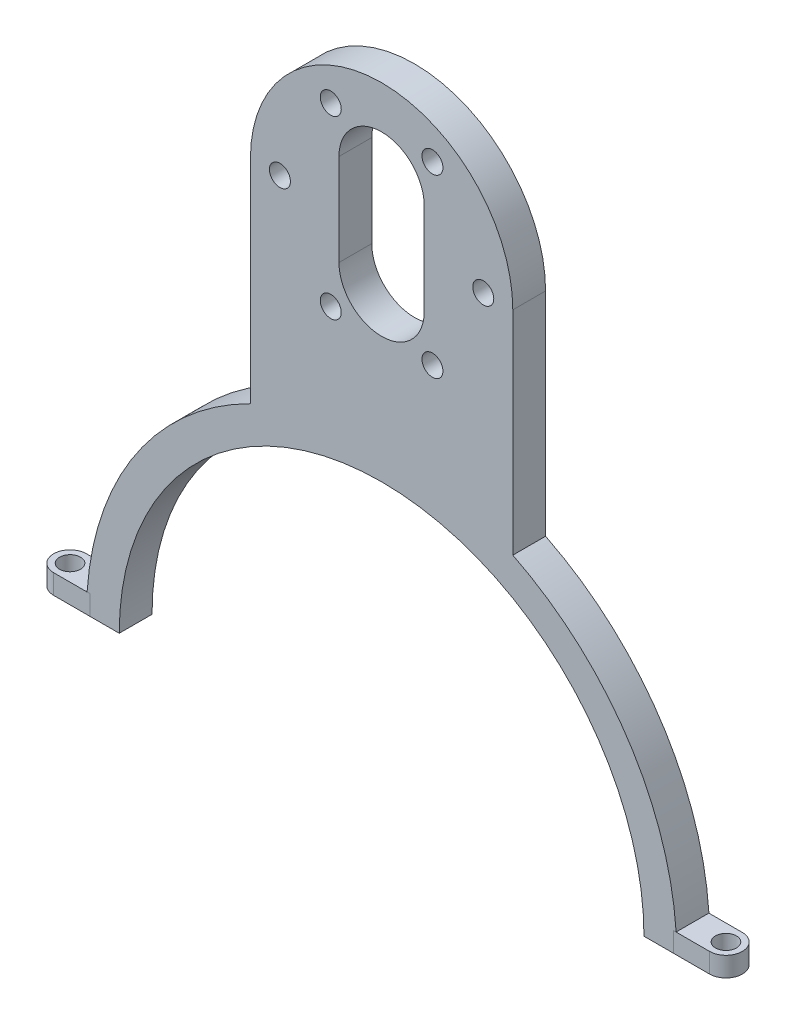
from build123d import *

# Parameters (mm, degrees)
SKETCH_1_R               = 40
EXTRUDE_1_DEPTH          = 5
SKETCH_2_R               = 1.6
CUT_EXTRUDE_1_DEPTH      = 5
SKETCH_3_R               = 2.6
CUT_EXTRUDE_2_DEPTH      = 2
SKETCH_4_W               = 99.26232013
SKETCH_4_H               = 51.828911565
CUT_EXTRUDE_3_DEPTH      = 1
CUT_EXTRUDE_3_DEPTH_BACK = 6
SKETCH_5_R               = 1.6
EXTRUDE_2_DEPTH          = 3
EXTRUDE_2_2_DEPTH        = 3


with BuildPart() as part:
    # 草图1 → 凸台-拉伸1 (new body)
    with BuildSketch(Plane.XY):
        with BuildLine():
            Line((-20, 72.7), (-20, 40.311288741))
            ThreePointArc((-20, 40.311288741), (0, -45), (20, 40.311288741))
            Line((20, 40.311288741), (20, 72.7))
            ThreePointArc((20, 72.7), (0, 92.7), (-20, 72.7))
        make_face()
        Circle(SKETCH_1_R, mode=Mode.SUBTRACT)
    extrude(amount=EXTRUDE_1_DEPTH)

    # 草图2 → 切除-拉伸1 (cut, symmetric)
    with BuildSketch(Plane.XY.offset(5)):
        with Locations((-7.75, 86.123393759)):
            Circle(SKETCH_2_R)
        with Locations((7.75, 86.123393759)):
            Circle(SKETCH_2_R)
        with Locations((15.5, 72.7)):
            Circle(SKETCH_2_R)
        with Locations((7.75, 59.276606241)):
            Circle(SKETCH_2_R)
        with Locations((-7.75, 59.276606241)):
            Circle(SKETCH_2_R)
        with Locations((-15.5, 72.7)):
            Circle(SKETCH_2_R)
        with BuildLine():
            Line((6.5, 79.7), (6.5, 65.7))
            ThreePointArc((6.5, 65.7), (0, 59.2), (-6.5, 65.7))
            Line((-6.5, 65.7), (-6.5, 79.7))
            ThreePointArc((-6.5, 79.7), (0, 86.2), (6.5, 79.7))
        make_face()
    extrude(amount=CUT_EXTRUDE_1_DEPTH, both=True, mode=Mode.SUBTRACT)

    # 草图3 → 切除-拉伸2 (cut)
    with BuildSketch(Plane(origin=(0, 0, 0), x_dir=(-1, 0, 0), z_dir=(0, 0, -1))):
        with Locations((-7.75, 86.123393759)):
            Circle(SKETCH_3_R)
        with Locations((7.75, 86.123393759)):
            Circle(SKETCH_3_R)
        with Locations((15.5, 72.7)):
            Circle(SKETCH_3_R)
        with Locations((7.75, 59.276606241)):
            Circle(SKETCH_3_R)
        with Locations((-7.75, 59.276606241)):
            Circle(SKETCH_3_R)
        with Locations((-15.5, 72.7)):
            Circle(SKETCH_3_R)
    extrude(amount=-CUT_EXTRUDE_2_DEPTH, mode=Mode.SUBTRACT)

    # 草图4 → 切除-拉伸3 (cut, two sides)
    with BuildSketch(Plane.XY.offset(5)) as cut_extrude_3_sk:
        with Locations((4.631160065, -25.914455783)):
            Rectangle(SKETCH_4_W, SKETCH_4_H)
    extrude(amount=CUT_EXTRUDE_3_DEPTH, mode=Mode.SUBTRACT)
    extrude(cut_extrude_3_sk.sketch, amount=-CUT_EXTRUDE_3_DEPTH_BACK, mode=Mode.SUBTRACT)


with BuildPart() as body_2:
    # 草图5 → 凸台-拉伸2 (new body)
    with BuildSketch(Plane.XZ):
        with BuildLine():
            Line((-44.472472542, 5.000003), (-50, 5.000003))
            ThreePointArc((-50, 5.000003), (-52.5, 2.500003), (-50, 3e-06))
            Line((-50, 3e-06), (-44.472472542, 3e-06))
            Line((-44.472472542, 3e-06), (-44.472472542, 5.000003))
        make_face()
        with Locations((-50, 2.500003)):
            Circle(SKETCH_5_R, mode=Mode.SUBTRACT)
    extrude(amount=-EXTRUDE_2_DEPTH)


with BuildPart() as body_3:
    # 草图5 → Extrude 2 2 (new body)
    with BuildSketch(Plane.XZ):
        with BuildLine():
            Line((44.472472542, 3e-06), (50, 3e-06))
            ThreePointArc((50, 3e-06), (52.5, 2.500003), (50, 5.000003))
            Line((50, 5.000003), (44.472472542, 5.000003))
            Line((44.472472542, 5.000003), (44.472472542, 3e-06))
        make_face()
        with Locations((50, 2.500003)):
            Circle(SKETCH_5_R, mode=Mode.SUBTRACT)
    extrude(amount=-EXTRUDE_2_2_DEPTH)


solid = Compound([part.part, body_2.part, body_3.part])
